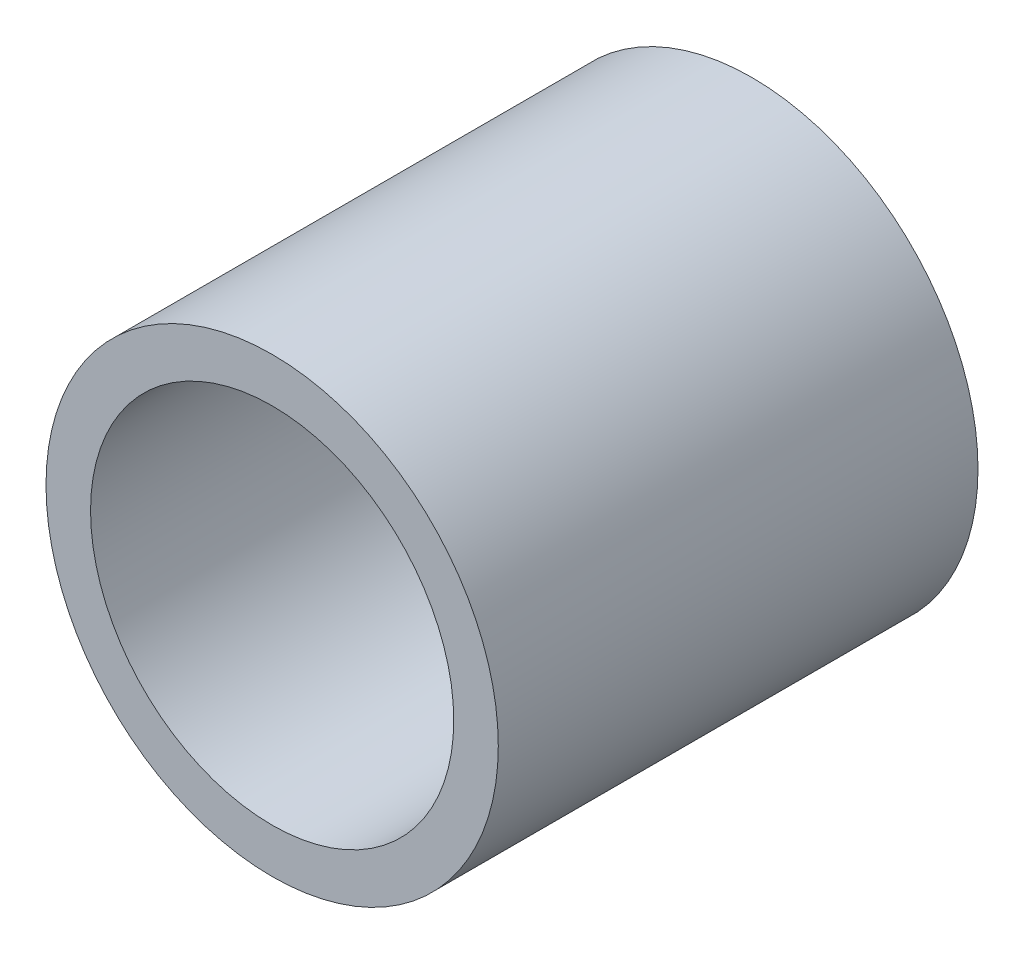
from build123d import *

# Parameters (mm, degrees)
SKETCH1_R           = 16.5
BOSS_EXTRUDE1_DEPTH = 35
SKETCH2_R           = 13.25
CUT_EXTRUDE1_DEPTH  = 35


with BuildPart() as part:
    # Sketch1 → Boss-Extrude1 (new body)
    with BuildSketch(Plane.XY):
        Circle(SKETCH1_R)
    extrude(amount=BOSS_EXTRUDE1_DEPTH)

    # Sketch2 → Cut-Extrude1 (cut)
    with BuildSketch(Plane(origin=(0, 0, 0), x_dir=(-1, 0, 0), z_dir=(0, 0, -1))):
        Circle(SKETCH2_R)
    extrude(amount=-CUT_EXTRUDE1_DEPTH, mode=Mode.SUBTRACT)


solid = part.part
